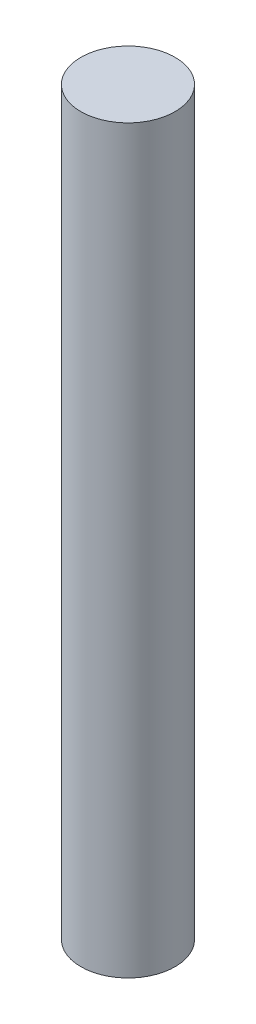
from build123d import *

# Parameters (mm, degrees)
SKETCH1_R           = 15.9
BOSS_EXTRUDE1_DEPTH = 250


with BuildPart() as part:
    # Sketch1 → Boss-Extrude1 (new body)
    with BuildSketch(Plane(origin=(0, 0, 0), x_dir=(1, 0, 0), z_dir=(0, 1, 0))):
        Circle(SKETCH1_R)
    extrude(amount=BOSS_EXTRUDE1_DEPTH)


solid = part.part
